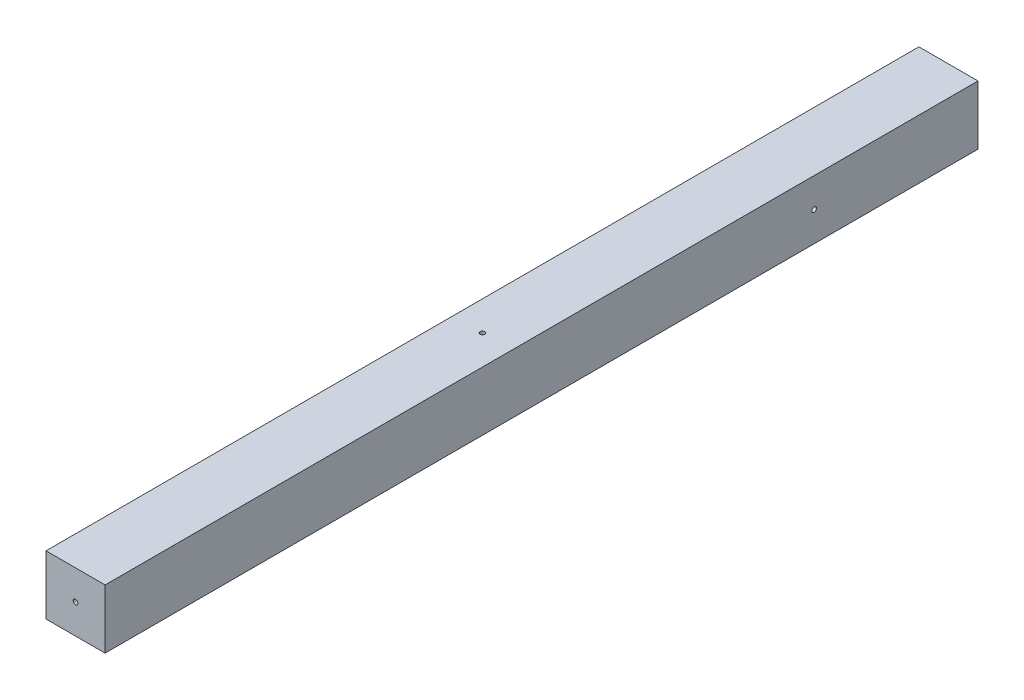
from build123d import *

# Parameters (mm, degrees)
ESQUISSE1_W             = 44
ESQUISSE1_H             = 44
BOSS_EXTRU_1_DEPTH      = 650
ESQUISSE2_R             = 1.75
ENL_V_MAT_EXTRU_1_DEPTH = 60
ESQUISSE3_R             = 1.75
ENL_V_MAT_EXTRU_2_DEPTH = 44
ESQUISSE4_R             = 1.75
ENL_V_MAT_EXTRU_3_DEPTH = 60


with BuildPart() as part:
    # Esquisse1 → Boss.-Extru.1 (new body)
    with BuildSketch(Plane.XY):
        Rectangle(ESQUISSE1_W, ESQUISSE1_H)
    extrude(amount=BOSS_EXTRU_1_DEPTH)

    # Esquisse2 → Enlèv. mat.-Extru.1 (cut)
    with BuildSketch(Plane(origin=(0, 0, 650), x_dir=(-1, 0, 0), z_dir=(0, 0, -1))):
        Circle(ESQUISSE2_R)
    extrude(amount=ENL_V_MAT_EXTRU_1_DEPTH, mode=Mode.SUBTRACT)

    # Esquisse3 → Enlèv. mat.-Extru.2 (cut)
    with BuildSketch(Plane.YZ.offset(-22)):
        with Locations((0, 122)):
            Circle(ESQUISSE3_R)
    extrude(amount=ENL_V_MAT_EXTRU_2_DEPTH, mode=Mode.SUBTRACT)

    # Esquisse4 → Enlèv. mat.-Extru.3 (cut)
    with BuildSketch(Plane.XZ.offset(22)):
        with Locations((0, 347)):
            Circle(ESQUISSE4_R)
    extrude(amount=-ENL_V_MAT_EXTRU_3_DEPTH, mode=Mode.SUBTRACT)


solid = part.part
